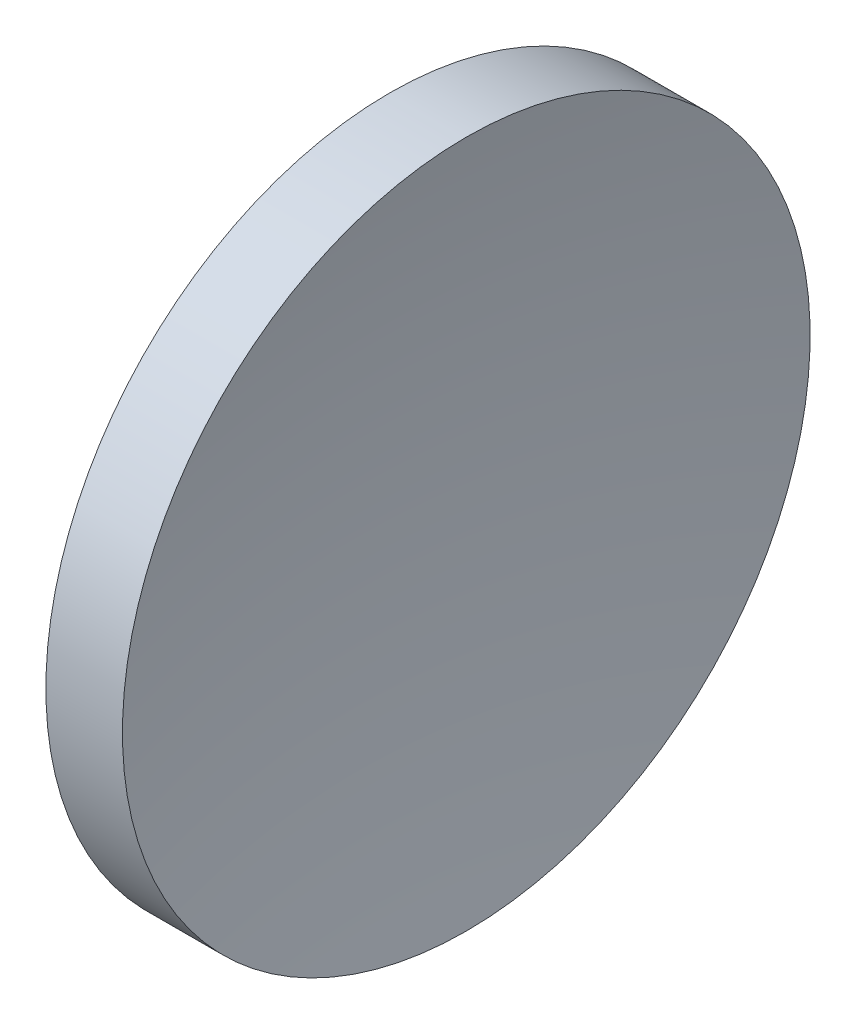
from build123d import *


with BuildPart() as part:
    # 草图1 → 旋转1 (revolve)
    with BuildSketch(Plane.XY, mode=Mode.PRIVATE) as revolve_1_sk:
        with BuildLine():
            Line((114.97544726, 65.157451827), (114.97544726, 85.157451827))
            Line((114.97544726, 85.157451827), (119.430433567, 85.157451827))
            ThreePointArc((119.430433567, 85.157451827), (117.965355777, 75.205112891), (117.47544726, 65.157451827))
            Line((117.47544726, 65.157451827), (114.97544726, 65.157451827))
        make_face()
    revolve(revolve_1_sk.sketch.rotate(Axis((110.014789249, 65.157451827, 0), (1, 0, 0)), 180), axis=Axis((110.014789249, 65.157451827, 0), (1, 0, 0)))  # turned: the seam where the file's is


solid = part.part
